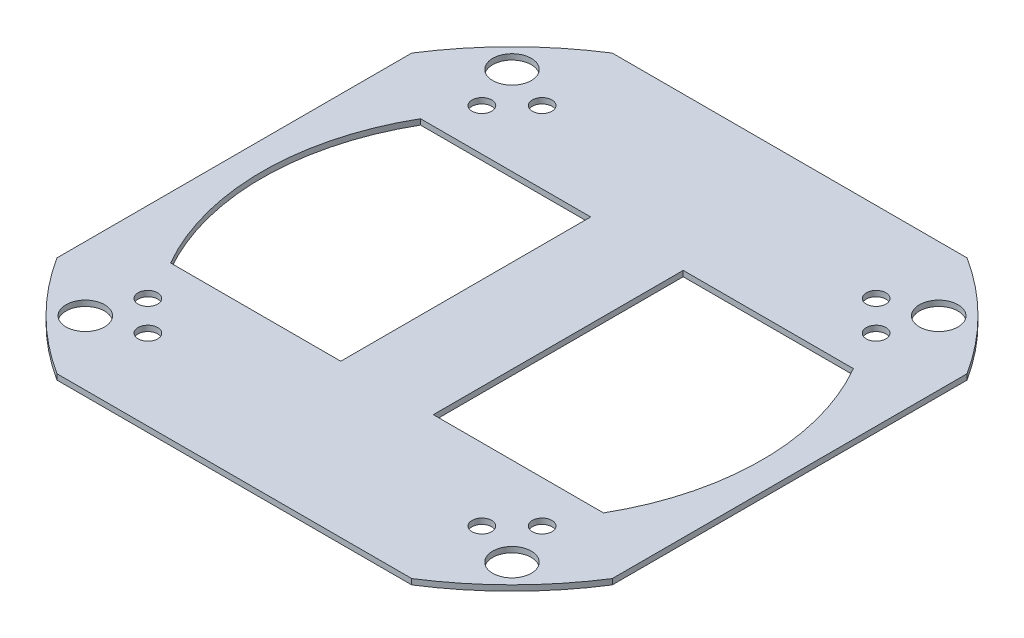
from build123d import *

# Parameters (mm, degrees)
SKETCH_3_R          = 178
EXTRUDE_3_DEPTH     = 3
SKETCH_4_R          = 10.414
SKETCH_4_R_2        = 5.3
CUT_EXTRUDE_1_DEPTH = 10
CUT_EXTRUDE_2_DEPTH = 10


with BuildPart() as part:
    # 草图3 → 凸台-拉伸3 (new body)
    with BuildSketch(Plane(origin=(0, 0, 0), x_dir=(1, 0, 0), z_dir=(0, 1, 0))):
        Circle(SKETCH_3_R)
        with BuildLine():
            Line((-25, 33.75), (-25, -67.5))
            Line((-25, -67.5), (-116.913429511, -67.5))
            ThreePointArc((-116.913429511, -67.5), (-135, 0), (-116.913429511, 67.5))
            Line((-116.913429511, 67.5), (-25, 67.5))
            Line((-25, 67.5), (-25, 33.75))
        make_face(mode=Mode.SUBTRACT)
        with BuildLine():
            Line((25, 33.75), (25, 67.5))
            Line((25, 67.5), (116.913429511, 67.5))
            ThreePointArc((116.913429511, 67.5), (135, 0), (116.913429511, -67.5))
            Line((116.913429511, -67.5), (25, -67.5))
            Line((25, -67.5), (25, 33.75))
        make_face(mode=Mode.SUBTRACT)
    extrude(amount=EXTRUDE_3_DEPTH)

    # 草图4 → 切除-拉伸1 (cut)
    with BuildSketch(Plane(origin=(0, 3, 0), x_dir=(1, 0, 0), z_dir=(0, 1, 0))):
        with Locations((115.258405333, 115.258405333)):
            Circle(SKETCH_4_R)
        with Locations((115.258405333, -115.258405333)):
            Circle(SKETCH_4_R)
        with Locations((-115.258405333, -115.258405333)):
            Circle(SKETCH_4_R)
        with Locations((-115.258405333, 115.258405333)):
            Circle(SKETCH_4_R)
        with Locations((-90.216925784, -106.480381752)):
            Circle(SKETCH_4_R_2)
        with Locations((-106.480381752, -90.216925784)):
            Circle(SKETCH_4_R_2)
        with Locations((-106.480381752, 90.216925784)):
            Circle(SKETCH_4_R_2)
        with Locations((-90.216925784, 106.480381752)):
            Circle(SKETCH_4_R_2)
        with Locations((90.216925784, 106.480381752)):
            Circle(SKETCH_4_R_2)
        with Locations((106.480381752, 90.216925784)):
            Circle(SKETCH_4_R_2)
        with Locations((106.480381752, -90.216925784)):
            Circle(SKETCH_4_R_2)
        with Locations((90.216925784, -106.480381752)):
            Circle(SKETCH_4_R_2)
    extrude(amount=-CUT_EXTRUDE_1_DEPTH, mode=Mode.SUBTRACT)

    # 草图5 → 切除-拉伸2 (cut)
    with BuildSketch(Plane(origin=(0, 3, 0), x_dir=(1, 0, 0), z_dir=(0, 1, 0))):
        with BuildLine():
            Line((95.833188406, 150), (0, 150))
            Line((0, 150), (-95.833188406, 150))
            ThreePointArc((-95.833188406, 150), (0, 178), (95.833188406, 150))
        make_face()
        with BuildLine():
            Line((150, 95.833188406), (150, 0))
            Line((150, 0), (150, -95.833188406))
            ThreePointArc((150, -95.833188406), (178, 0), (150, 95.833188406))
        make_face()
        with BuildLine():
            Line((95.833188406, -150), (0, -150))
            Line((0, -150), (-95.833188406, -150))
            ThreePointArc((-95.833188406, -150), (0, -178), (95.833188406, -150))
        make_face()
        with BuildLine():
            Line((-150, 0), (-150, -95.833188406))
            ThreePointArc((-150, -95.833188406), (-178, 0), (-150, 95.833188406))
            Line((-150, 95.833188406), (-150, 0))
        make_face()
    extrude(amount=-CUT_EXTRUDE_2_DEPTH, mode=Mode.SUBTRACT)


solid = part.part
